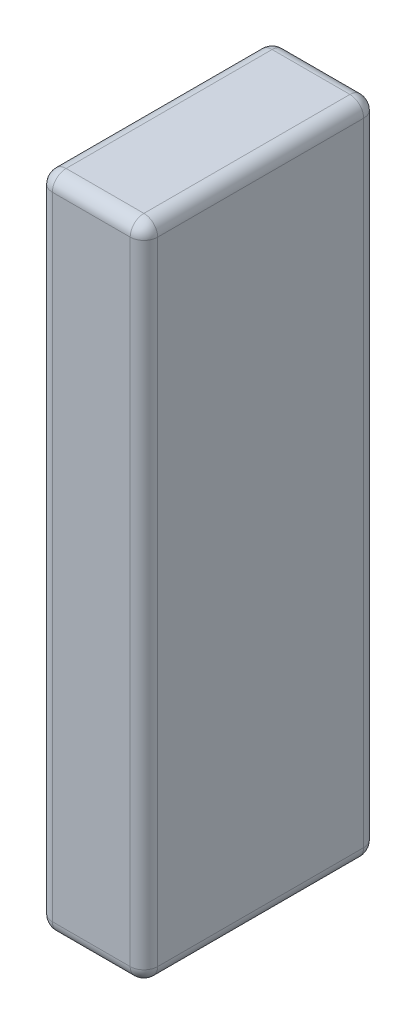
from build123d import *

# Parameters (mm, degrees)
SKETCH1_W           = 23
SKETCH1_H           = 51
BOSS_EXTRUDE1_DEPTH = 144
FILLET1_R           = 3


with BuildPart() as part:
    # Sketch1 → Boss-Extrude1 (new body)
    with BuildSketch(Plane(origin=(0, 0, 0), x_dir=(1, 0, 0), z_dir=(0, 1, 0))):
        with Locations((11.5, 25.5)):
            Rectangle(SKETCH1_W, SKETCH1_H)
    extrude(amount=BOSS_EXTRUDE1_DEPTH)

    # Fillet1
    fillet1_edges = [part.edges().sort_by_distance(p)[0] for p in [
        (23, 144, -25.5),
        (11.5, 144, -51),
        (0, 144, -25.5),
        (11.5, 0, -51),
        (23, 0, -25.5),
        (11.5, 0, 0),
        (0, 0, -25.5),
        (11.5, 144, 0),
        (0, 72, -51),
        (23, 72, -51),
        (23, 72, 0),
        (0, 72, 0),
    ]]
    fillet(fillet1_edges, radius=FILLET1_R)


solid = part.part
